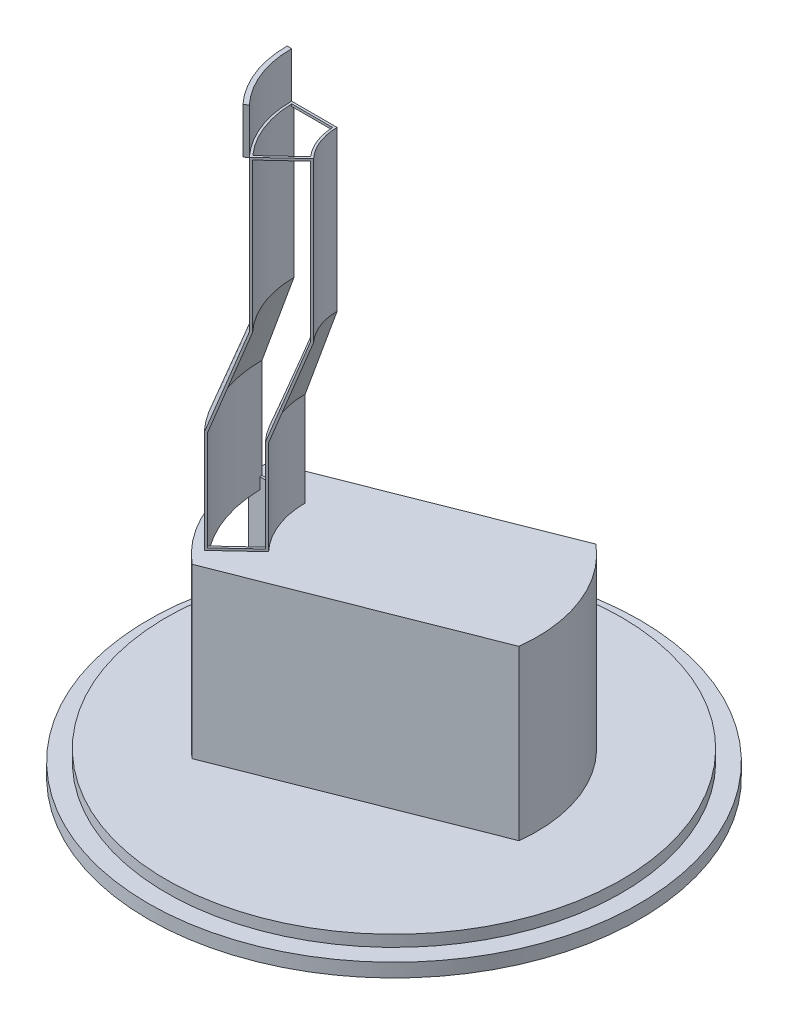
from build123d import *
from build123d.topology import SkipClean

# Parameters (mm, degrees)
REVOLVE2_ANGLE      = 43
CUT_EXTRUDE3_DEPTH  = 3
CUT_EXTRUDE4_DEPTH  = 7
BOSS_EXTRUDE1_DEPTH = 20
SKETCH6_R           = 63
BOSS_EXTRUDE2_DEPTH = 4
CUT_EXTRUDE5_DEPTH  = 4
BOSS_EXTRUDE3_DEPTH = 70
SKETCH10_R          = 100
BOSS_EXTRUDE4_DEPTH = 5
SKETCH11_R          = 108
BOSS_EXTRUDE6_DEPTH = 6
CUT_EXTRUDE6_DEPTH  = 74


with BuildPart() as part:
    # Sketch1 → Revolve2 (revolve)
    with BuildSketch(Plane.XY):
        Polygon((-25, 0), (-45, 0), (-45, -66.473460386), (-59.022513649, -105), (-59.022513649, -150), (-39.022513649, -150), (-39.022513649, -108.526539614), (-25, -70), align=None)
        Polygon((-44, -1), (-44, -66.649787367), (-58.022513649, -105.176326981), (-58.022513649, -149), (-40.022513649, -149), (-40.022513649, -108.350212633), (-26, -69.823673019), (-26, -1), align=None, mode=Mode.SUBTRACT)
    revolve(axis=Axis((0, 0, 0), (0, 1, 0)), revolution_arc=REVOLVE2_ANGLE)

    # 3DSketch2 → Cut-Extrude3 (cut)
    with BuildSketch(Plane(origin=(-25.980762114, 0, 1), x_dir=(-0.23623107763582377, 0, 0.9716969064265963), z_dir=(0, 1, 0))):
        with BuildLine():
            Line((0, 0), (4.254019193, -17.498194274))
            ThreePointArc((4.254019193, -17.498194274), (18.231392391, -10.961020186), (29.092223071, 0))
            Line((29.092223071, 0), (14.047290588, 9.89613504))
            ThreePointArc((14.047290588, 9.89613504), (7.864802638, 3.754067883), (0, 0))
        make_face()
    extrude(amount=-CUT_EXTRUDE3_DEPTH, mode=Mode.SUBTRACT)

    # 3DSketch3 → Cut-Extrude4 (cut)
    with BuildSketch(Plane(origin=(-58.013895664, -150, 1), x_dir=(0.9998514717105971, 0, -0.017234689383714308), z_dir=(0, -1, 0))):
        with BuildLine():
            Line((0, 0), (18.001202849, 0.310291227))
            ThreePointArc((18.001202849, 0.310291227), (20.537591079, 14.024342363), (27.625813139, 26.035402761))
            Line((27.625813139, 26.035402761), (14.248948694, 38.085260946))
            ThreePointArc((14.248948694, 38.085260946), (3.678864709, 20.33174636), (0, 0))
        make_face()
    extrude(amount=-CUT_EXTRUDE4_DEPTH, mode=Mode.SUBTRACT)

    # Sketch6 → Boss-Extrude2 (add)
    with BuildSketch(Plane.XZ.offset(150)):
        with Locations(Location((0, 0, 0), (0, 0, 270))):
            Circle(SKETCH6_R)
    extrude(amount=BOSS_EXTRUDE2_DEPTH)

    # 3DSketch3_2 → Cut-Extrude5 (cut)
    with BuildSketch(Plane(origin=(-58.013895664, -150, 1), x_dir=(0.9998514717105971, 0, -0.017234689383714308), z_dir=(0, -1, 0))):
        with BuildLine():
            Line((0, 0), (18.001202849, 0.310291227))
            ThreePointArc((18.001202849, 0.310291227), (20.537591079, 14.024342363), (27.625813139, 26.035402761))
            Line((27.625813139, 26.035402761), (14.248948694, 38.085260946))
            ThreePointArc((14.248948694, 38.085260946), (3.678864709, 20.33174636), (0, 0))
        make_face()
    extrude(amount=CUT_EXTRUDE5_DEPTH, mode=Mode.SUBTRACT)

    # Sketch7 → Boss-Extrude3 (add)
    with SkipClean():  # the faces are left unmerged after this step: merging them gives an invalid solid
        with BuildSketch(Plane(origin=(0, -154, 0), x_dir=(-1, 0, 0), z_dir=(0, -1, 0))):
            with BuildLine():
                Line((17.08897941, -15.393725433), (46.808943602, -42.165421839))
                ThreePointArc((46.808943602, -42.165421839), (-58.632015581, 23.049658325), (62.992062992, -1))
                Line((62.992062992, -1), (22.978250586, -1))
                ThreePointArc((22.978250586, -1), (21.287098507, -8.709732323), (17.08897941, -15.393725433))
            make_face()
        extrude(amount=BOSS_EXTRUDE3_DEPTH)

    # Sketch10 → Boss-Extrude4 (add)
    with SkipClean():  # the faces are left unmerged after this step: merging them gives an invalid solid
        with BuildSketch(Plane(origin=(0, -224, 0), x_dir=(-1, 0, 0), z_dir=(0, -1, 0))):
            with Locations(Location((0, 0, 0), (0, 0, 90))):
                Circle(SKETCH10_R)
        extrude(amount=BOSS_EXTRUDE4_DEPTH)

    # Sketch11 → Boss-Extrude6 (add)
    with SkipClean():  # the faces are left unmerged after this step: merging them gives an invalid solid
        with BuildSketch(Plane(origin=(0, -229, 0), x_dir=(-1, 0, 0), z_dir=(0, -1, 0))):
            with Locations(Location((0, 0, 0), (0, 0, 90))):
                Circle(SKETCH11_R)
        extrude(amount=BOSS_EXTRUDE6_DEPTH)

    # Sketch14 → Cut-Extrude6 (cut)
    with SkipClean():  # the faces are left unmerged after this step: merging them gives an invalid solid
        with BuildSketch(Plane(origin=(0, -150, 0), x_dir=(1, 0, 0), z_dir=(0, 1, 0))):
            with BuildLine():
                ThreePointArc((40.548752884, 48.216165749), (-23.089577284, 58.616306783), (-62.538826487, 7.608888329))
                Line((-62.538826487, 7.608888329), (40.548752884, 48.216165749))
            make_face()
            with BuildLine():
                Line((62.538826487, -7.608888329), (-40.548752884, -48.216165749))
                ThreePointArc((-40.548752884, -48.216165749), (23.089577284, -58.616306783), (62.538826487, -7.608888329))
            make_face()
        extrude(amount=-CUT_EXTRUDE6_DEPTH, mode=Mode.SUBTRACT)


with BuildPart() as body_2:
    # Sketch5 → Boss-Extrude1 (new body)
    with BuildSketch(Plane(origin=(0, 0, 0), x_dir=(1, 0, 0), z_dir=(0, 1, 0))):
        with BuildLine():
            Line((-45, 0), (-47, 0))
            ThreePointArc((-47, 0), (-43.729625695, -17.225557656), (-34.373623976, -32.053922923))
            Line((-34.373623976, -32.053922923), (-32.910916573, -30.689926203))
            ThreePointArc((-32.910916573, -30.689926203), (-41.868790559, -16.492555203), (-45, 0))
        make_face()
    extrude(amount=BOSS_EXTRUDE1_DEPTH)


solid = Compound([part.part, body_2.part])
